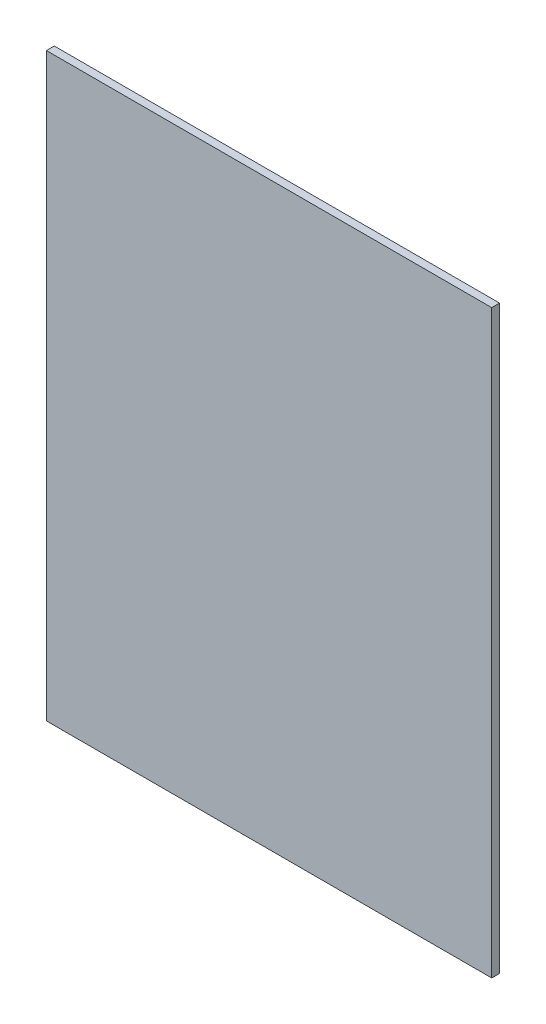
from build123d import *

# Parameters (mm, degrees)
SKETCH1_W           = 360.426
SKETCH1_H           = 469.9
BOSS_EXTRUDE1_DEPTH = 6.35


with BuildPart() as part:
    # Sketch1 → Boss-Extrude1 (new body)
    with BuildSketch(Plane.XY):
        Rectangle(SKETCH1_W, SKETCH1_H)
    extrude(amount=BOSS_EXTRUDE1_DEPTH)


solid = part.part
